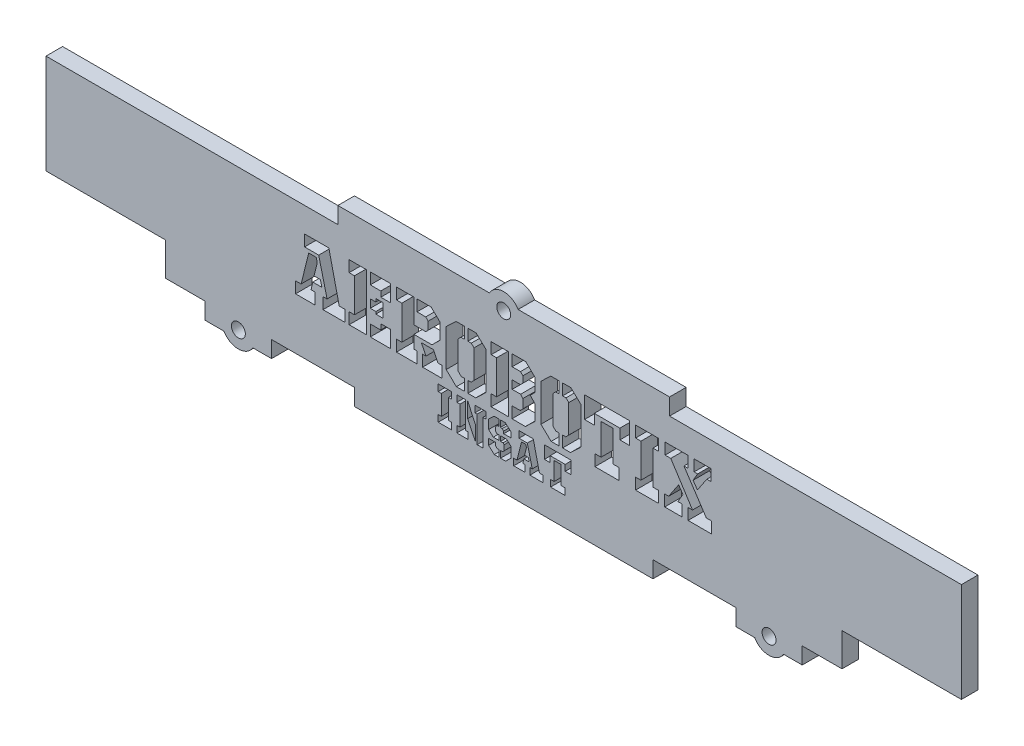
from build123d import *

# Parameters (mm, degrees)
SKETCH1_W           = 204
SKETCH1_H           = 40
SKETCH1_W_2         = 100
SKETCH1_H_2         = 5
SKETCH1_W_3         = 20
SKETCH1_W_4         = 90
BOSS_EXTRUDE1_DEPTH = 5
SKETCH2_R           = 2.1
CUT_EXTRUDE1_DEPTH  = 5
BOSS_EXTRUDE2_DEPTH = 5
SKETCH4_W           = 2
SKETCH4_H           = 40
CUT_EXTRUDE2_DEPTH  = 5
SKETCH5_W           = 5
SKETCH5_H           = 40
BOSS_EXTRUDE3_DEPTH = 2
SKETCH6_W           = 5
SKETCH6_H           = 25
BOSS_EXTRUDE4_DEPTH = 36
SKETCH7_W           = 5
SKETCH7_H           = 40
BOSS_EXTRUDE5_DEPTH = 2
SKETCH8_W           = 5
SKETCH8_H           = 25
BOSS_EXTRUDE6_DEPTH = 36
SKETCH9_W           = 36
SKETCH9_H           = 5
BOSS_EXTRUDE7_DEPTH = 15
CUT_EXTRUDE3_DEPTH  = 10
SKETCH11_W          = 36
SKETCH11_H          = 10
CUT_EXTRUDE4_DEPTH  = 10


with BuildPart() as part:
    # Sketch1 → Boss-Extrude1 (new body)
    with BuildSketch(Plane.XY):
        with Locations((102, 20)):
            Rectangle(SKETCH1_W, SKETCH1_H)
        with Locations((102, 42.5)):
            Rectangle(SKETCH1_W_2, SKETCH1_H_2)
        with Locations((22, -2.5)):
            Rectangle(SKETCH1_W_3, SKETCH1_H_2)
        with Locations((102, -2.5)):
            Rectangle(SKETCH1_W_4, SKETCH1_H_2)
        with Locations((182, -2.5)):
            Rectangle(SKETCH1_W_3, SKETCH1_H_2)
    extrude(amount=BOSS_EXTRUDE1_DEPTH)

    # Sketch2 → Cut-Extrude1 (cut)
    with BuildSketch(Plane.XY.offset(5)):
        with Locations((102, 42.5)):
            Circle(SKETCH2_R)
        with Locations((182, -2.5)):
            Circle(SKETCH2_R)
        with Locations((22, -2.5)):
            Circle(SKETCH2_R)
    extrude(amount=-CUT_EXTRUDE1_DEPTH, mode=Mode.SUBTRACT)

    # Sketch3 → Boss-Extrude2 (add)
    with BuildSketch(Plane.XY.offset(5)):
        with BuildLine():
            Line((106.330127019, 45), (97.669872981, 45))
            ThreePointArc((97.669872981, 45), (102, 47.5), (106.330127019, 45))
        make_face()
        with BuildLine():
            Line((186.330127019, -5), (177.669872981, -5))
            ThreePointArc((177.669872981, -5), (182, -7.5), (186.330127019, -5))
        make_face()
        with BuildLine():
            Line((17.669872981, -5), (26.330127019, -5))
            ThreePointArc((26.330127019, -5), (22, -7.5), (17.669872981, -5))
        make_face()
    extrude(amount=-BOSS_EXTRUDE2_DEPTH)

    # Sketch4 → Cut-Extrude2 (cut)
    with BuildSketch(Plane.XY.offset(5)):
        with Locations((203, 20)):
            Rectangle(SKETCH4_W, SKETCH4_H)
        with Locations((1, 20)):
            Rectangle(SKETCH4_W, SKETCH4_H)
    extrude(amount=-CUT_EXTRUDE2_DEPTH, mode=Mode.SUBTRACT)

    # Sketch5 → Boss-Extrude3 (add)
    with BuildSketch(Plane.ZY.offset(-2)):
        with Locations((2.5, 20)):
            Rectangle(SKETCH5_W, SKETCH5_H)
    extrude(amount=BOSS_EXTRUDE3_DEPTH)

    # Sketch6 → Boss-Extrude4 (add)
    with BuildSketch(Plane.ZY):
        with Locations((2.5, 27.5)):
            Rectangle(SKETCH6_W, SKETCH6_H)
    extrude(amount=BOSS_EXTRUDE4_DEPTH)

    # Sketch7 → Boss-Extrude5 (add)
    with BuildSketch(Plane(origin=(202, 0, 0), x_dir=(0, 0, -1), z_dir=(1, 0, 0))):
        with Locations((-2.5, 20)):
            Rectangle(SKETCH7_W, SKETCH7_H)
    extrude(amount=BOSS_EXTRUDE5_DEPTH)

    # Sketch8 → Boss-Extrude6 (add)
    with BuildSketch(Plane(origin=(204, 0, 0), x_dir=(0, 0, -1), z_dir=(1, 0, 0))):
        with Locations((-2.5, 27.5)):
            Rectangle(SKETCH8_W, SKETCH8_H)
    extrude(amount=BOSS_EXTRUDE6_DEPTH)

    # Sketch9 → Boss-Extrude7 (add)
    with BuildSketch(Plane.XZ.offset(-15)):
        with Locations((222, 2.5)):
            Rectangle(SKETCH9_W, SKETCH9_H)
        with Locations((-18, 2.5)):
            Rectangle(SKETCH9_W, SKETCH9_H)
    extrude(amount=BOSS_EXTRUDE7_DEPTH)

    # Sketch10 → Cut-Extrude3 (cut)
    with BuildSketch(Plane.XY.offset(5)):
        Polygon((41.958125, 32.543718722), (49.27875, 32.543718722), (52.409583333, 18.943718722), (54.222916667, 18.943718722), (54.222916667, 15.543718722), (47.515, 15.543718722), (47.515, 18.943718722), (48.740416667, 18.943718722), (46.21875, 29.143718722), (41.958125, 29.143718722), align=None)
        Polygon((40.90625, 18.943718722), (43.229583333, 28.191010388), (45.482083333, 28.191010388), (45.776041667, 26.891218722), (44.823333333, 23.023718722), (46.732291667, 23.023718722), (47.19625, 21.210385388), (44.430208333, 21.210385388), (43.916666667, 18.943718722), (45.067708333, 18.943718722), (45.067708333, 15.543718722), (39.241666667, 15.543718722), (39.241666667, 18.943718722), align=None)
        Polygon((55.388125, 32.543718722), (60.633333333, 32.543718722), (60.633333333, 15.543718722), (55.388125, 15.543718722), (55.388125, 18.943718722), (57.006666667, 18.943718722), (57.006666667, 29.143718722), (55.388125, 29.143718722), align=None)
        Polygon((67.886666667, 27.503927055), (64.94, 27.503927055), (64.94, 29.143718722), (61.766666667, 29.143718722), (61.766666667, 32.543718722), (67.886666667, 32.543718722), align=None)
        Polygon((61.766666667, 15.543718722), (61.766666667, 18.943718722), (64.94, 18.943718722), (64.94, 20.587052055), (67.886666667, 20.587052055), (67.886666667, 15.543718722), align=None)
        Polygon((61.766666667, 23.023718722), (61.766666667, 25.517052055), (63.438333333, 25.517052055), (63.438333333, 26.423718722), (65.62, 26.423718722), (65.62, 22.343718722), (63.438333333, 22.343718722), (63.438333333, 23.023718722), align=None)
        Polygon((75.866041667, 29.143718722), (75.866041667, 32.543718722), (80.108958333, 32.543718722), (82.846666667, 29.901635388), (82.846666667, 25.244343722), (80.3675, 22.797052055), (74.913333333, 22.797052055), (74.913333333, 18.943718722), (75.890833333, 18.943718722), (75.890833333, 15.543718722), (69.668125, 15.543718722), (69.668125, 18.943718722), (71.286666667, 18.943718722), (71.286666667, 29.143718722), (69.668125, 29.143718722), (69.668125, 32.543718722), (74.913333333, 32.543718722), (74.913333333, 25.290385388), (78.490416667, 25.290385388), (79.22, 26.030593722), (79.22, 28.403510388), (78.486875, 29.143718722), align=None)
        Polygon((77.165833333, 21.759343722), (80.81375, 21.759343722), (82.184375, 18.943718722), (83.409791667, 18.943718722), (83.409791667, 15.543718722), (77.54125, 15.543718722), (77.54125, 18.943718722), (78.56125, 18.943718722), align=None)
        Polygon((87.627916667, 32.543718722), (90.170833333, 32.543718722), (90.170833333, 29.143718722), (89.118958333, 29.143718722), (88.286666667, 28.329135388), (88.286666667, 19.832677055), (89.168541667, 18.943718722), (90.170833333, 18.943718722), (90.170833333, 15.543718722), (87.727083333, 15.543718722), (84.66, 18.483302055), (84.66, 29.703302055), align=None)
        Polygon((92.214375, 29.143718722), (91.187291667, 29.143718722), (91.187291667, 32.543718722), (93.705416667, 32.543718722), (96.673333333, 29.703302055), (96.673333333, 18.483302055), (93.577916667, 15.543718722), (91.187291667, 15.543718722), (91.187291667, 18.943718722), (92.164791667, 18.943718722), (93.046666667, 19.832677055), (93.046666667, 28.329135388), align=None)
        Polygon((104.546458333, 29.143718722), (104.546458333, 32.543718722), (108.622916667, 32.543718722), (111.406666667, 29.898093722), (111.406666667, 25.839343722), (109.986458333, 24.433302055), (111.406666667, 22.949343722), (111.406666667, 18.288510388), (108.534375, 15.543718722), (104.496875, 15.543718722), (104.496875, 18.943718722), (106.997291667, 18.943718722), (107.78, 19.772468722), (107.78, 22.471218722), (107.092916667, 23.250385388), (104.546458333, 23.250385388), (104.546458333, 25.743718722), (107.046875, 25.743718722), (107.78, 26.473302055), (107.78, 28.414135388), (107.046875, 29.143718722), align=None)
        Polygon((98.228125, 32.543718722), (103.473333333, 32.543718722), (103.473333333, 15.543718722), (98.228125, 15.543718722), (98.228125, 18.943718722), (99.846666667, 18.943718722), (99.846666667, 29.143718722), (98.228125, 29.143718722), align=None)
        Polygon((116.187916667, 32.543718722), (118.730833333, 32.543718722), (118.730833333, 29.143718722), (117.678958333, 29.143718722), (116.846666667, 28.329135388), (116.846666667, 19.832677055), (117.728541667, 18.943718722), (118.730833333, 18.943718722), (118.730833333, 15.543718722), (116.287083333, 15.543718722), (113.22, 18.483302055), (113.22, 29.703302055), align=None)
        Polygon((120.774375, 29.143718722), (119.747291667, 29.143718722), (119.747291667, 32.543718722), (122.265416667, 32.543718722), (125.233333333, 29.703302055), (125.233333333, 18.483302055), (122.137916667, 15.543718722), (119.747291667, 15.543718722), (119.747291667, 18.943718722), (120.724791667, 18.943718722), (121.606666667, 19.832677055), (121.606666667, 28.329135388), align=None)
        Polygon((139.966666667, 26.285593722), (137.02, 26.285593722), (137.02, 29.370385388), (129.313333333, 29.370385388), (129.313333333, 26.285593722), (126.366666667, 26.285593722), (126.366666667, 32.770385388), (139.966666667, 32.770385388), align=None)
        Polygon((131.353333333, 18.943718722), (131.353333333, 28.297260388), (134.98, 28.297260388), (134.98, 18.943718722), (136.814583333, 18.943718722), (136.814583333, 15.543718722), (129.51875, 15.543718722), (129.51875, 18.943718722), align=None)
        Polygon((148.608333333, 29.143718722), (146.993333333, 29.143718722), (146.993333333, 18.943718722), (148.608333333, 18.943718722), (148.608333333, 15.543718722), (141.751666667, 15.543718722), (141.751666667, 18.943718722), (143.366666667, 18.943718722), (143.366666667, 29.143718722), (141.751666667, 29.143718722), (141.751666667, 32.543718722), (148.608333333, 32.543718722), align=None)
        Polygon((163.09375, 18.943718722), (164.659166667, 18.943718722), (164.659166667, 15.543718722), (157.582916667, 15.543718722), (157.582916667, 18.943718722), (158.92875, 18.943718722), (152.369583333, 29.143718722), (150.655416667, 29.143718722), (150.655416667, 32.543718722), (157.558125, 32.543718722), (157.558125, 29.143718722), (156.33625, 29.143718722), align=None)
        Polygon((151.732083333, 18.943718722), (154.746041667, 23.448718722), (156.0175, 21.539760388), (154.522916667, 18.943718722), (155.723541667, 18.943718722), (155.723541667, 15.543718722), (150.535, 15.543718722), (150.535, 18.943718722), align=None)
        Polygon((164.535208333, 29.143718722), (163.238958333, 29.143718722), (160.398541667, 24.907885388), (159.102291667, 26.795593722), (160.472916667, 29.143718722), (159.421041667, 29.143718722), (159.421041667, 32.543718722), (164.535208333, 32.543718722), align=None)
        Polygon((86.283333333, 11.523609343), (85.333333333, 11.523609343), (85.333333333, 5.523609343), (86.283333333, 5.523609343), (86.283333333, 3.523609343), (82.25, 3.523609343), (82.25, 5.523609343), (83.2, 5.523609343), (83.2, 11.523609343), (82.25, 11.523609343), (82.25, 13.523609343), (86.283333333, 13.523609343), align=None)
        Polygon((87.866666667, 13.523609343), (90.533333333, 13.523609343), (90.533333333, 5.523609343), (91.195833333, 5.523609343), (91.195833333, 3.523609343), (87.866666667, 3.523609343), (87.866666667, 5.523609343), (88.8, 5.523609343), (88.8, 11.523609343), (87.866666667, 11.523609343), align=None)
        Polygon((96.697916667, 11.523609343), (95.733333333, 11.523609343), (95.733333333, 3.523609343), (94, 3.523609343), (94, 11.523609343), (93.339583333, 11.523609343), (93.339583333, 13.523609343), (96.697916667, 13.523609343), align=None)
        Polygon((91.1125, 13.58402601), (93.422916667, 8.64652601), (93.422916667, 4.167359343), (91.1125, 8.875692676), align=None)
        Polygon((101.052083333, 7.923609343), (101.052083333, 9.39027601), (102.91875, 9.39027601), (104.266666667, 8.136109343), (104.266666667, 5.15277601), (102.577083333, 3.523609343), (101.052083333, 3.523609343), (101.052083333, 5.523609343), (101.672916667, 5.523609343), (102.133333333, 5.998609343), (102.133333333, 7.581942676), (101.802083333, 7.923609343), align=None)
        Polygon((99.077083333, 13.523609343), (100.622916667, 13.523609343), (100.622916667, 11.523609343), (100.047916667, 11.523609343), (99.6, 11.094442676), (99.6, 9.719442676), (99.960416667, 9.39027601), (100.622916667, 9.39027601), (100.622916667, 7.923609343), (98.854166667, 7.923609343), (97.466666667, 9.22777601), (97.466666667, 11.97777601), align=None)
        Polygon((100.060416667, 5.523609343), (100.622916667, 5.523609343), (100.622916667, 3.523609343), (99.152083333, 3.523609343), (97.466666667, 5.104859343), (97.466666667, 6.92152601), (99.6, 6.92152601), (99.6, 5.986109343), align=None)
        Polygon((104.133333333, 12.00902601), (104.133333333, 10.386109343), (102, 10.386109343), (102, 11.092359343), (101.554166667, 11.523609343), (101.00625, 11.523609343), (101.00625, 13.523609343), (102.51875, 13.523609343), align=None)
        Polygon((106.614583333, 13.523609343), (110.920833333, 13.523609343), (112.7625, 5.523609343), (113.829166667, 5.523609343), (113.829166667, 3.523609343), (109.883333333, 3.523609343), (109.883333333, 5.523609343), (110.604166667, 5.523609343), (109.120833333, 11.523609343), (106.614583333, 11.523609343), align=None)
        Polygon((105.995833333, 5.523609343), (107.3625, 10.963192676), (108.6875, 10.963192676), (108.860416667, 10.198609343), (108.3, 7.923609343), (109.422916667, 7.923609343), (109.695833333, 6.856942676), (108.06875, 6.856942676), (107.766666667, 5.523609343), (108.44375, 5.523609343), (108.44375, 3.523609343), (105.016666667, 3.523609343), (105.016666667, 5.523609343), align=None)
        Polygon((122.266666667, 9.842359343), (120.533333333, 9.842359343), (120.533333333, 11.656942676), (116, 11.656942676), (116, 9.842359343), (114.266666667, 9.842359343), (114.266666667, 13.656942676), (122.266666667, 13.656942676), align=None)
        Polygon((117.2, 5.523609343), (117.2, 11.025692676), (119.333333333, 11.025692676), (119.333333333, 5.523609343), (120.4125, 5.523609343), (120.4125, 3.523609343), (116.120833333, 3.523609343), (116.120833333, 5.523609343), align=None)
    extrude(amount=-CUT_EXTRUDE3_DEPTH, mode=Mode.SUBTRACT)

    # Sketch11 → Cut-Extrude4 (cut)
    with BuildSketch(Plane.XY.offset(5)):
        with Locations((222, 5)):
            Rectangle(SKETCH11_W, SKETCH11_H)
        with Locations((-18, 5)):
            Rectangle(SKETCH11_W, SKETCH11_H)
    extrude(amount=-CUT_EXTRUDE4_DEPTH, mode=Mode.SUBTRACT)


solid = part.part
